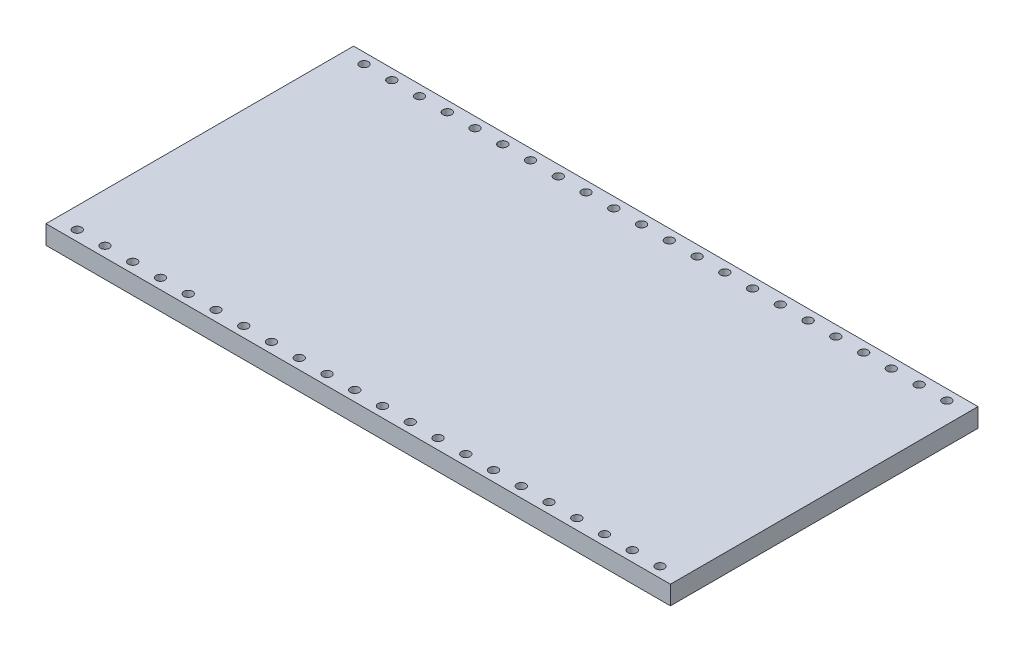
from build123d import *

# Parameters (mm, degrees)
SKETCH1_W                = 57.15
SKETCH1_H                = 28.15
BOSS_EXTRUDE1_DEPTH      = 1.72
SKETCH2_R                = 0.4
CUT_EXTRUDE1_DEPTH       = 2.72
LPATTERN1_COUNT          = 22
LPATTERN1_PITCH          = 2.54
MIRROR1_COPY_1_SKETCH_R  = 0.4
MIRROR1_COPY_1_DEPTH     = 2.72
MIRROR1_COPY_2_SKETCH_R  = 0.4
MIRROR1_COPY_2_DEPTH     = 2.72
MIRROR1_COPY_3_SKETCH_R  = 0.4
MIRROR1_COPY_3_DEPTH     = 2.72
MIRROR1_COPY_4_SKETCH_R  = 0.4
MIRROR1_COPY_4_DEPTH     = 2.72
MIRROR1_COPY_5_SKETCH_R  = 0.4
MIRROR1_COPY_5_DEPTH     = 2.72
MIRROR1_COPY_6_SKETCH_R  = 0.4
MIRROR1_COPY_6_DEPTH     = 2.72
MIRROR1_COPY_7_SKETCH_R  = 0.4
MIRROR1_COPY_7_DEPTH     = 2.72
MIRROR1_COPY_8_SKETCH_R  = 0.4
MIRROR1_COPY_8_DEPTH     = 2.72
MIRROR1_COPY_9_SKETCH_R  = 0.4
MIRROR1_COPY_9_DEPTH     = 2.72
MIRROR1_COPY_10_SKETCH_R = 0.4
MIRROR1_COPY_10_DEPTH    = 2.72
MIRROR1_COPY_11_SKETCH_R = 0.4
MIRROR1_COPY_11_DEPTH    = 2.72
MIRROR1_COPY_12_SKETCH_R = 0.4
MIRROR1_COPY_12_DEPTH    = 2.72
MIRROR1_COPY_13_SKETCH_R = 0.4
MIRROR1_COPY_13_DEPTH    = 2.72
MIRROR1_COPY_14_SKETCH_R = 0.4
MIRROR1_COPY_14_DEPTH    = 2.72
MIRROR1_COPY_15_SKETCH_R = 0.4
MIRROR1_COPY_15_DEPTH    = 2.72
MIRROR1_COPY_16_SKETCH_R = 0.4
MIRROR1_COPY_16_DEPTH    = 2.72
MIRROR1_COPY_17_SKETCH_R = 0.4
MIRROR1_COPY_17_DEPTH    = 2.72
MIRROR1_COPY_18_SKETCH_R = 0.4
MIRROR1_COPY_18_DEPTH    = 2.72
MIRROR1_COPY_19_SKETCH_R = 0.4
MIRROR1_COPY_19_DEPTH    = 2.72
MIRROR1_COPY_20_SKETCH_R = 0.4
MIRROR1_COPY_20_DEPTH    = 2.72
MIRROR1_COPY_21_SKETCH_R = 0.4
MIRROR1_COPY_21_DEPTH    = 2.72


with BuildPart() as part:
    # Sketch1 → Boss-Extrude1 (new body)
    with BuildSketch(Plane(origin=(0, 0, 0), x_dir=(1, 0, 0), z_dir=(0, 1, 0))):
        Rectangle(SKETCH1_W, SKETCH1_H)
    extrude(amount=BOSS_EXTRUDE1_DEPTH)

    # Sketch2 → Cut-Extrude1 (cut, through all)
    with BuildSketch(Plane(origin=(0, 1.72, 0), x_dir=(1, 0, 0), z_dir=(0, 1, 0))):
        with Locations((26.675, 13.125)):
            Circle(SKETCH2_R)
    cut_extrude1 = extrude(amount=-CUT_EXTRUDE1_DEPTH, mode=Mode.SUBTRACT)

    # LPattern1: Cut-Extrude1 ×22
    with Locations(*[(-i * LPATTERN1_PITCH, 0, 0) for i in range(1, LPATTERN1_COUNT)]):
        add(cut_extrude1, mode=Mode.SUBTRACT)

    # Mirror1: Cut-Extrude1 across plane
    add(cut_extrude1.mirror(Plane.XY), mode=Mode.SUBTRACT)

    # Mirror1 copy 1 sketch → Mirror1 copy 1 (cut, through all)
    with BuildSketch(Plane(origin=(-2.54, 1.72, 0), x_dir=(1, 0, 0), z_dir=(0, 1, 0))):
        with Locations((26.675, -13.125)):
            Circle(MIRROR1_COPY_1_SKETCH_R)
    extrude(amount=-MIRROR1_COPY_1_DEPTH, mode=Mode.SUBTRACT)

    # Mirror1 copy 2 sketch → Mirror1 copy 2 (cut, through all)
    with BuildSketch(Plane(origin=(-5.08, 1.72, 0), x_dir=(1, 0, 0), z_dir=(0, 1, 0))):
        with Locations((26.675, -13.125)):
            Circle(MIRROR1_COPY_2_SKETCH_R)
    extrude(amount=-MIRROR1_COPY_2_DEPTH, mode=Mode.SUBTRACT)

    # Mirror1 copy 3 sketch → Mirror1 copy 3 (cut, through all)
    with BuildSketch(Plane(origin=(-7.62, 1.72, 0), x_dir=(1, 0, 0), z_dir=(0, 1, 0))):
        with Locations((26.675, -13.125)):
            Circle(MIRROR1_COPY_3_SKETCH_R)
    extrude(amount=-MIRROR1_COPY_3_DEPTH, mode=Mode.SUBTRACT)

    # Mirror1 copy 4 sketch → Mirror1 copy 4 (cut, through all)
    with BuildSketch(Plane(origin=(-10.16, 1.72, 0), x_dir=(1, 0, 0), z_dir=(0, 1, 0))):
        with Locations((26.675, -13.125)):
            Circle(MIRROR1_COPY_4_SKETCH_R)
    extrude(amount=-MIRROR1_COPY_4_DEPTH, mode=Mode.SUBTRACT)

    # Mirror1 copy 5 sketch → Mirror1 copy 5 (cut, through all)
    with BuildSketch(Plane(origin=(-12.7, 1.72, 0), x_dir=(1, 0, 0), z_dir=(0, 1, 0))):
        with Locations((26.675, -13.125)):
            Circle(MIRROR1_COPY_5_SKETCH_R)
    extrude(amount=-MIRROR1_COPY_5_DEPTH, mode=Mode.SUBTRACT)

    # Mirror1 copy 6 sketch → Mirror1 copy 6 (cut, through all)
    with BuildSketch(Plane(origin=(-15.24, 1.72, 0), x_dir=(1, 0, 0), z_dir=(0, 1, 0))):
        with Locations((26.675, -13.125)):
            Circle(MIRROR1_COPY_6_SKETCH_R)
    extrude(amount=-MIRROR1_COPY_6_DEPTH, mode=Mode.SUBTRACT)

    # Mirror1 copy 7 sketch → Mirror1 copy 7 (cut, through all)
    with BuildSketch(Plane(origin=(-17.78, 1.72, 0), x_dir=(1, 0, 0), z_dir=(0, 1, 0))):
        with Locations((26.675, -13.125)):
            Circle(MIRROR1_COPY_7_SKETCH_R)
    extrude(amount=-MIRROR1_COPY_7_DEPTH, mode=Mode.SUBTRACT)

    # Mirror1 copy 8 sketch → Mirror1 copy 8 (cut, through all)
    with BuildSketch(Plane(origin=(-20.32, 1.72, 0), x_dir=(1, 0, 0), z_dir=(0, 1, 0))):
        with Locations((26.675, -13.125)):
            Circle(MIRROR1_COPY_8_SKETCH_R)
    extrude(amount=-MIRROR1_COPY_8_DEPTH, mode=Mode.SUBTRACT)

    # Mirror1 copy 9 sketch → Mirror1 copy 9 (cut, through all)
    with BuildSketch(Plane(origin=(-22.86, 1.72, 0), x_dir=(1, 0, 0), z_dir=(0, 1, 0))):
        with Locations((26.675, -13.125)):
            Circle(MIRROR1_COPY_9_SKETCH_R)
    extrude(amount=-MIRROR1_COPY_9_DEPTH, mode=Mode.SUBTRACT)

    # Mirror1 copy 10 sketch → Mirror1 copy 10 (cut, through all)
    with BuildSketch(Plane(origin=(-25.4, 1.72, 0), x_dir=(1, 0, 0), z_dir=(0, 1, 0))):
        with Locations((26.675, -13.125)):
            Circle(MIRROR1_COPY_10_SKETCH_R)
    extrude(amount=-MIRROR1_COPY_10_DEPTH, mode=Mode.SUBTRACT)

    # Mirror1 copy 11 sketch → Mirror1 copy 11 (cut, through all)
    with BuildSketch(Plane(origin=(-27.94, 1.72, 0), x_dir=(1, 0, 0), z_dir=(0, 1, 0))):
        with Locations((26.675, -13.125)):
            Circle(MIRROR1_COPY_11_SKETCH_R)
    extrude(amount=-MIRROR1_COPY_11_DEPTH, mode=Mode.SUBTRACT)

    # Mirror1 copy 12 sketch → Mirror1 copy 12 (cut, through all)
    with BuildSketch(Plane(origin=(-30.48, 1.72, 0), x_dir=(1, 0, 0), z_dir=(0, 1, 0))):
        with Locations((26.675, -13.125)):
            Circle(MIRROR1_COPY_12_SKETCH_R)
    extrude(amount=-MIRROR1_COPY_12_DEPTH, mode=Mode.SUBTRACT)

    # Mirror1 copy 13 sketch → Mirror1 copy 13 (cut, through all)
    with BuildSketch(Plane(origin=(-33.02, 1.72, 0), x_dir=(1, 0, 0), z_dir=(0, 1, 0))):
        with Locations((26.675, -13.125)):
            Circle(MIRROR1_COPY_13_SKETCH_R)
    extrude(amount=-MIRROR1_COPY_13_DEPTH, mode=Mode.SUBTRACT)

    # Mirror1 copy 14 sketch → Mirror1 copy 14 (cut, through all)
    with BuildSketch(Plane(origin=(-35.56, 1.72, 0), x_dir=(1, 0, 0), z_dir=(0, 1, 0))):
        with Locations((26.675, -13.125)):
            Circle(MIRROR1_COPY_14_SKETCH_R)
    extrude(amount=-MIRROR1_COPY_14_DEPTH, mode=Mode.SUBTRACT)

    # Mirror1 copy 15 sketch → Mirror1 copy 15 (cut, through all)
    with BuildSketch(Plane(origin=(-38.1, 1.72, 0), x_dir=(1, 0, 0), z_dir=(0, 1, 0))):
        with Locations((26.675, -13.125)):
            Circle(MIRROR1_COPY_15_SKETCH_R)
    extrude(amount=-MIRROR1_COPY_15_DEPTH, mode=Mode.SUBTRACT)

    # Mirror1 copy 16 sketch → Mirror1 copy 16 (cut, through all)
    with BuildSketch(Plane(origin=(-40.64, 1.72, 0), x_dir=(1, 0, 0), z_dir=(0, 1, 0))):
        with Locations((26.675, -13.125)):
            Circle(MIRROR1_COPY_16_SKETCH_R)
    extrude(amount=-MIRROR1_COPY_16_DEPTH, mode=Mode.SUBTRACT)

    # Mirror1 copy 17 sketch → Mirror1 copy 17 (cut, through all)
    with BuildSketch(Plane(origin=(-43.18, 1.72, 0), x_dir=(1, 0, 0), z_dir=(0, 1, 0))):
        with Locations((26.675, -13.125)):
            Circle(MIRROR1_COPY_17_SKETCH_R)
    extrude(amount=-MIRROR1_COPY_17_DEPTH, mode=Mode.SUBTRACT)

    # Mirror1 copy 18 sketch → Mirror1 copy 18 (cut, through all)
    with BuildSketch(Plane(origin=(-45.72, 1.72, 0), x_dir=(1, 0, 0), z_dir=(0, 1, 0))):
        with Locations((26.675, -13.125)):
            Circle(MIRROR1_COPY_18_SKETCH_R)
    extrude(amount=-MIRROR1_COPY_18_DEPTH, mode=Mode.SUBTRACT)

    # Mirror1 copy 19 sketch → Mirror1 copy 19 (cut, through all)
    with BuildSketch(Plane(origin=(-48.26, 1.72, 0), x_dir=(1, 0, 0), z_dir=(0, 1, 0))):
        with Locations((26.675, -13.125)):
            Circle(MIRROR1_COPY_19_SKETCH_R)
    extrude(amount=-MIRROR1_COPY_19_DEPTH, mode=Mode.SUBTRACT)

    # Mirror1 copy 20 sketch → Mirror1 copy 20 (cut, through all)
    with BuildSketch(Plane(origin=(-50.8, 1.72, 0), x_dir=(1, 0, 0), z_dir=(0, 1, 0))):
        with Locations((26.675, -13.125)):
            Circle(MIRROR1_COPY_20_SKETCH_R)
    extrude(amount=-MIRROR1_COPY_20_DEPTH, mode=Mode.SUBTRACT)

    # Mirror1 copy 21 sketch → Mirror1 copy 21 (cut, through all)
    with BuildSketch(Plane(origin=(-53.34, 1.72, 0), x_dir=(1, 0, 0), z_dir=(0, 1, 0))):
        with Locations((26.675, -13.125)):
            Circle(MIRROR1_COPY_21_SKETCH_R)
    extrude(amount=-MIRROR1_COPY_21_DEPTH, mode=Mode.SUBTRACT)


solid = part.part
